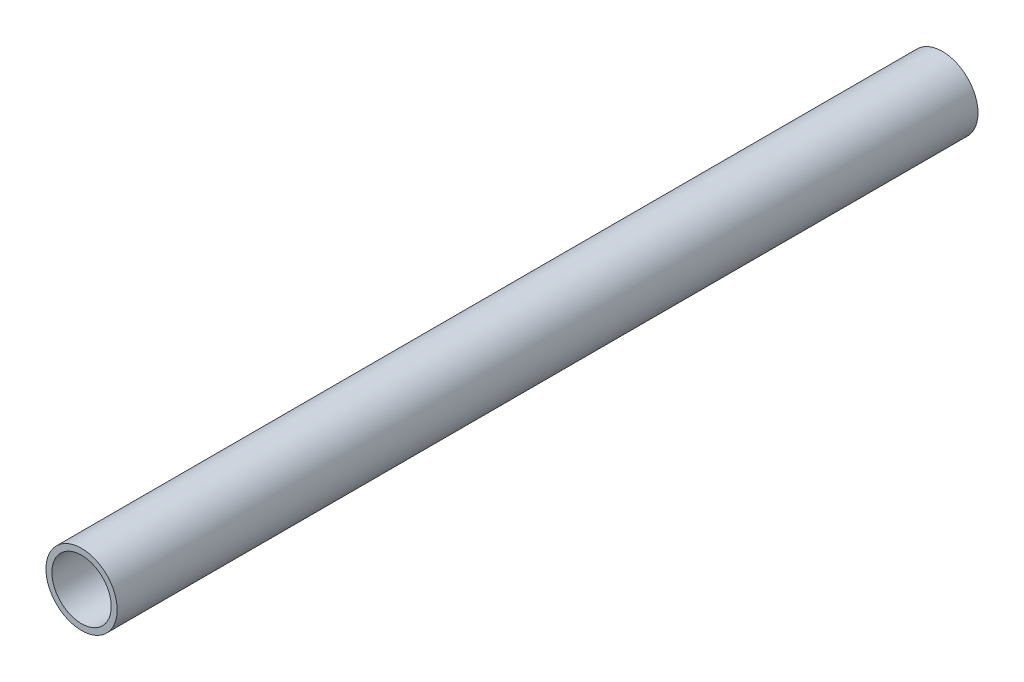
from build123d import *

# Parameters (mm, degrees)
SKETCH1_R           = 6
SKETCH1_R_2         = 5
BOSS_EXTRUDE1_DEPTH = 145


with BuildPart() as part:
    # Sketch1 → Boss-Extrude1 (new body)
    with BuildSketch(Plane.XY):
        with Locations((-80, -58)):
            Circle(SKETCH1_R)
        with Locations((-80, -58)):
            Circle(SKETCH1_R_2, mode=Mode.SUBTRACT)
    extrude(amount=BOSS_EXTRUDE1_DEPTH)


solid = part.part
